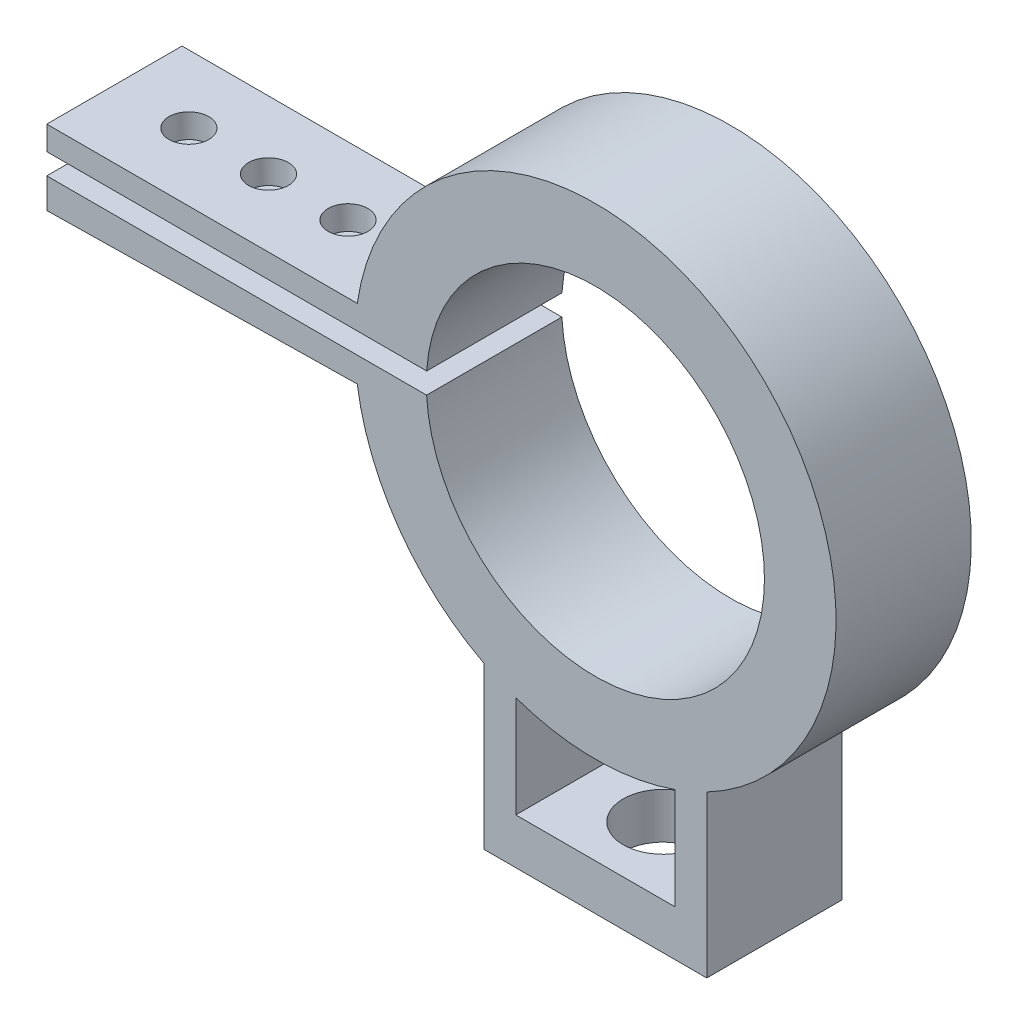
from build123d import *

# Parameters (mm, degrees)
SKETCH1_W           = 20
SKETCH1_H           = 5.75
BOSS_EXTRUDE1_DEPTH = 17
SKETCH2_R           = 5
CUT_EXTRUDE2_DEPTH  = 7
SKETCH4_R           = 2.5
CUT_EXTRUDE3_DEPTH  = 17


with BuildPart() as part:
    # Sketch1 → Boss-Extrude1 (new body)
    with BuildSketch(Plane.XY):
        with BuildLine():
            ThreePointArc((-30.225116888, -1.226706604), (-30.119790355, -2.803699153), (-29.932240793, -4.373037976))
            Line((-29.932240793, -4.373037976), (-20.825403989, -4.226706604))
            ThreePointArc((-20.825403989, -4.226706604), (-21.073436119, -2.733640452), (-21.21456318, -1.226706604))
            Line((-21.21456318, -1.226706604), (-30.225116888, -1.226706604))
        make_face()
        with BuildLine():
            Line((-68.950810556, -1.226706604), (-68.950810556, -5))
            Line((-68.950810556, -5), (-29.932240793, -4.373037976))
            ThreePointArc((-29.932240793, -4.373037976), (-30.119790355, -2.803699153), (-30.225116888, -1.226706604))
            Line((-30.225116888, -1.226706604), (-68.950810556, -1.226706604))
        make_face()
        with BuildLine():
            Line((-68.950810556, 4.405365931), (-68.950810556, 1.405365931))
            Line((-68.950810556, 1.405365931), (-30.217336855, 1.405365931))
            ThreePointArc((-30.217336855, 1.405365931), (-30.109804839, 2.908977923), (-29.927499912, 4.405365931))
            Line((-29.927499912, 4.405365931), (-68.950810556, 4.405365931))
        make_face()
        with BuildLine():
            ThreePointArc((-29.927499912, 4.405365931), (-30.109804839, 2.908977923), (-30.217336855, 1.405365931))
            Line((-30.217336855, 1.405365931), (-21.203477229, 1.405365931))
            ThreePointArc((-21.203477229, 1.405365931), (-21.049424337, 2.91277103), (-20.788344114, 4.405365931))
            Line((-20.788344114, 4.405365931), (-29.927499912, 4.405365931))
        make_face()
        with BuildLine():
            ThreePointArc((21.25, 0), (15.0260191, -15.0260191), (0, -21.25))
            Line((0, -21.25), (10, -21.25))
            Line((10, -21.25), (14, -21.25))
            Line((14, -21.25), (14, -26.815340759))
            ThreePointArc((14, -26.815340759), (25.870470618, -15.677412095), (30.25, 0))
            ThreePointArc((30.25, 0), (2.20857733, 30.169267246), (-29.927499912, 4.405365931))
            Line((-29.927499912, 4.405365931), (-20.788344114, 4.405365931))
            ThreePointArc((-20.788344114, 4.405365931), (2.214744632, 21.134270894), (21.25, 0))
        make_face()
        with BuildLine():
            Line((-20.825403989, -4.226706604), (-29.932240793, -4.373037976))
            ThreePointArc((-29.932240793, -4.373037976), (-24.66626611, -17.511076957), (-14, -26.815340759))
            Line((-14, -26.815340759), (-14, -21.25))
            Line((-14, -21.25), (-10, -21.25))
            Line((-10, -21.25), (0, -21.25))
            ThreePointArc((0, -21.25), (-13.448884427, -16.452659592), (-20.825403989, -4.226706604))
        make_face()
        with BuildLine():
            Line((-14, -21.25), (-14, -26.815340759))
            ThreePointArc((-14, -26.815340759), (-12.03127812, -27.754474356), (-10, -28.549299466))
            Line((-10, -28.549299466), (-10, -21.25))
            Line((-10, -21.25), (-14, -21.25))
        make_face()
        with BuildLine():
            Line((10, -21.25), (0, -21.25))
            Line((0, -21.25), (-10, -21.25))
            Line((-10, -21.25), (-10, -28.549299466))
            ThreePointArc((-10, -28.549299466), (0, -30.25), (10, -28.549299466))
            Line((10, -28.549299466), (10, -21.25))
        make_face()
        with BuildLine():
            Line((14, -21.25), (10, -21.25))
            Line((10, -21.25), (10, -28.549299466))
            ThreePointArc((10, -28.549299466), (12.03127812, -27.754474356), (14, -26.815340759))
            Line((14, -26.815340759), (14, -21.25))
        make_face()
        with BuildLine():
            ThreePointArc((14, -26.815340759), (12.03127812, -27.754474356), (10, -28.549299466))
            Line((10, -28.549299466), (10, -41.310288198))
            Line((10, -41.310288198), (10, -47.060288198))
            Line((10, -47.060288198), (14, -47.060288198))
            Line((14, -47.060288198), (14, -26.815340759))
        make_face()
        with BuildLine():
            ThreePointArc((-10, -28.549299466), (-12.03127812, -27.754474356), (-14, -26.815340759))
            Line((-14, -26.815340759), (-14, -47.060288198))
            Line((-14, -47.060288198), (-10, -47.060288198))
            Line((-10, -47.060288198), (-10, -41.310288198))
            Line((-10, -41.310288198), (-10, -28.549299466))
        make_face()
        with Locations((0, -44.185288198)):
            Rectangle(SKETCH1_W, SKETCH1_H)
    extrude(amount=BOSS_EXTRUDE1_DEPTH)

    # Sketch2 → Cut-Extrude2 (cut)
    with BuildSketch(Plane.XZ.offset(47.060288198)):
        with Locations((0, 8.5)):
            Circle(SKETCH2_R)
    extrude(amount=-CUT_EXTRUDE2_DEPTH, mode=Mode.SUBTRACT)

    # Sketch4 → Cut-Extrude3 (cut)
    with BuildSketch(Plane(origin=(0.062522925, -3.89107316, 0), x_dir=(0.99987093, 0.016066225, 0), z_dir=(0.016066225, -0.99987093, 0))):
        with Locations((-49.510438917, 8.5)):
            Circle(SKETCH4_R)
        with Locations((-39.510438917, 8.5)):
            Circle(SKETCH4_R)
        with Locations((-59.510438917, 8.5)):
            Circle(SKETCH4_R)
    extrude(amount=-CUT_EXTRUDE3_DEPTH, mode=Mode.SUBTRACT)


solid = part.part
